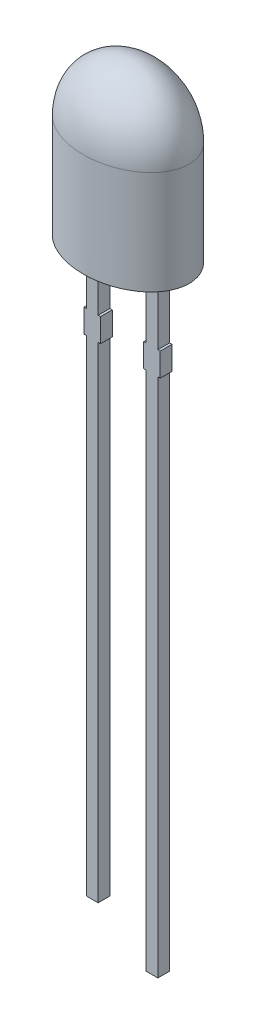
from build123d import *

# Parameters (mm, degrees)
SKETCH5_RX         = 2.6
SKETCH5_RY         = 1.9
EXTRUDE1_DEPTH     = 4.4
DOME3_HALF_AXIS_A  = 2.6
DOME3_HALF_AXIS_B  = 1.9
DOME3_HEIGHT       = 2.6
SKETCH3_W          = 0.5
SKETCH3_H          = 24.5
SKETCH3_H_2        = 26
SKETCH3_W_2        = 0.7
SKETCH3_H_3        = 1
EXTRUDE2_DEPTH     = 0.25
SKETCH6_W          = 0.025316456
SKETCH6_H          = 0.026582278
CUT_EXTRUDE1_DEPTH = 0.01


with BuildPart() as part:
    # Sketch5 → Extrude1 (new body)
    with BuildSketch(Plane(origin=(0, 0, 0), x_dir=(1, 0, 0), z_dir=(0, 1, 0))):
        with Locations(Location((0, 0), (0, 0, 180))):
            Ellipse(SKETCH5_RX, SKETCH5_RY)
    extrude(amount=EXTRUDE1_DEPTH)

    # Dome3: an elliptical dome of height H over an elliptical face of half axes A and B is half an ellipsoid of half axes A, B and H
    dome3_base = Plane((0, 4.4, 0), x_dir=(-1, 0, 0), z_dir=(0, 1, 0))  # on the face, x along the ellipse's major axis
    dome3_ball = dome3_base * scale(Sphere(1, mode=Mode.PRIVATE), by=(DOME3_HALF_AXIS_A, DOME3_HALF_AXIS_B, DOME3_HEIGHT), mode=Mode.PRIVATE)
    add(split(dome3_ball, bisect_by=dome3_base, keep=Keep.TOP, mode=Mode.PRIVATE))

    # Sketch3 → Extrude2 (add, symmetric)
    with BuildSketch(Plane.XY):
        with Locations((-1.27, -12.25)):
            Rectangle(SKETCH3_W, SKETCH3_H)
        with Locations((1.27, -13)):
            Rectangle(SKETCH3_W, SKETCH3_H_2)
        with Locations((-1.27, -3.35)):
            Rectangle(SKETCH3_W_2, SKETCH3_H_3)
        with Locations((1.27, -3.35)):
            Rectangle(SKETCH3_W_2, SKETCH3_H_3)
    extrude(amount=EXTRUDE2_DEPTH, both=True)

    # Sketch6 → Cut-Extrude1 (cut)
    with BuildSketch(Plane.XZ):
        Polygon((-0.686737084, 0.074683544), (-0.710194363, 0), (-0.734937243, 0), (-0.751353382, 0.050336234), (-0.76687949, 0), (-0.792611293, 0), (-0.815851009, 0.074683544), (-0.790673002, 0.074683544), (-0.77767854, 0.023200158), (-0.761262401, 0.074683544), (-0.739763192, 0.074683544), (-0.723445945, 0.023200158), (-0.71062949, 0.074683544), align=None)
        Polygon((-0.552559869, 0.074683544), (-0.576017148, 0), (-0.600760028, 0), (-0.617176167, 0.050336234), (-0.632702274, 0), (-0.658434078, 0), (-0.681673793, 0.074683544), (-0.656495787, 0.074683544), (-0.643501325, 0.023200158), (-0.627085186, 0.074683544), (-0.605585977, 0.074683544), (-0.58926873, 0.023200158), (-0.576452274, 0.074683544), align=None)
        Polygon((-0.418382654, 0.074683544), (-0.441839933, 0), (-0.466582812, 0), (-0.482998952, 0.050336234), (-0.498525059, 0), (-0.524256863, 0), (-0.547496578, 0.074683544), (-0.522318572, 0.074683544), (-0.50932411, 0.023200158), (-0.492907971, 0.074683544), (-0.471408762, 0.074683544), (-0.455091515, 0.023200158), (-0.442275059, 0.074683544), align=None)
        with Locations((-0.390534553, 0.013291139)):
            Rectangle(SKETCH6_W, SKETCH6_H)
        with BuildLine():
            add(Edge.make_bspline(
                [(-0.274078857, 0.031170886), (-0.274115346, 0.029948745), (-0.274186998, 0.027548867), (-0.274796715, 0.024041288), (-0.275790202, 0.020716583), (-0.277164319, 0.017553923), (-0.278953122, 0.014575304), (-0.281162712, 0.011795027), (-0.283727125, 0.009160227), (-0.286693335, 0.006754097), (-0.289973444, 0.00454972), (-0.29357102, 0.002652721), (-0.297449725, 0.001056238), (-0.301598311, -0.000282314), (-0.30604475, -0.001270894), (-0.310762279, -0.001994839), (-0.315755698, -0.002468169), (-0.319179276, -0.002510135), (-0.320934078, -0.002531646)],
                knots=[0, 0, 0, 0, 0.907352243, 1.781736951, 2.63548328, 3.47985091, 4.336556021, 5.208523475, 6.112432747, 7.062451073, 8.040435374, 9.043840564, 10.077958095, 11.152835584, 12.277940427, 13.457536469, 14.696825396, 16, 16, 16, 16], degree=3))
            add(Edge.make_bspline(
                [(-0.320934078, -0.002531646), (-0.322952334, -0.002507574), (-0.326861516, -0.002460949), (-0.332525041, -0.00203235), (-0.337793078, -0.001386211), (-0.342688793, -0.000419669), (-0.347293392, 0.000781096), (-0.35172666, 0.002072388), (-0.356007972, 0.003536803), (-0.358781061, 0.004636961), (-0.360154806, 0.005181962)],
                knots=[0, 0, 0, 0, 1.203215828, 2.33052265, 3.384689099, 4.366106119, 5.303329643, 6.221311756, 7.118865988, 8, 8, 8, 8], degree=3))
            Line((-0.360154806, 0.005181962), (-0.360154806, 0.029113924))
            Line((-0.360154806, 0.029113924), (-0.357306705, 0.029113924))
            add(Edge.make_bspline(
                [(-0.357306705, 0.029113924), (-0.355941391, 0.028032469), (-0.353218778, 0.025875908), (-0.348785545, 0.023113303), (-0.344137899, 0.02071114), (-0.339292428, 0.018737138), (-0.334395584, 0.017150814), (-0.329520206, 0.016057287), (-0.324754619, 0.015309938), (-0.321596049, 0.015229431), (-0.320044046, 0.015189873)],
                knots=[0, 0, 0, 0, 1.030622468, 2.055194264, 3.087043286, 4.125157485, 5.149848264, 6.130935704, 7.081611712, 8, 8, 8, 8], degree=3))
            add(Edge.make_bspline(
                [(-0.320044046, 0.015189873), (-0.31961527, 0.015190797), (-0.318697294, 0.015192774), (-0.317235767, 0.015320502), (-0.315583956, 0.015416078), (-0.313811447, 0.015623262), (-0.31201472, 0.015845123), (-0.31035232, 0.016220048), (-0.308842725, 0.016584915), (-0.307936204, 0.016952913), (-0.30750449, 0.017128165)],
                knots=[0, 0, 0, 0, 0.806402781, 1.726445712, 2.758724871, 3.919014682, 5.083870887, 6.16165551, 7.124521387, 8, 8, 8, 8], degree=3))
            add(Edge.make_bspline(
                [(-0.30750449, 0.017128165), (-0.307024927, 0.017356306), (-0.306082483, 0.017804654), (-0.304788884, 0.018614972), (-0.303621204, 0.019498437), (-0.302563832, 0.020463368), (-0.301689552, 0.021629118), (-0.301065685, 0.023037791), (-0.300720792, 0.024686809), (-0.300681768, 0.025862012), (-0.300661135, 0.026483386)],
                knots=[0, 0, 0, 0, 1.024747072, 2.013846092, 2.940605744, 3.850156746, 4.769278501, 5.73222711, 6.800942666, 8, 8, 8, 8], degree=3))
            add(Edge.make_bspline(
                [(-0.300661135, 0.026483386), (-0.30069298, 0.027029023), (-0.300755596, 0.028101907), (-0.301332789, 0.029637022), (-0.302242227, 0.03104619), (-0.303523817, 0.032314965), (-0.305116993, 0.033464498), (-0.307059376, 0.034446804), (-0.309309497, 0.035319991), (-0.310953568, 0.035737969), (-0.311816198, 0.035957278)],
                knots=[0, 0, 0, 0, 0.82557554, 1.623324704, 2.456147571, 3.35491006, 4.343819762, 5.427079081, 6.650009487, 8, 8, 8, 8], degree=3))
            add(Edge.make_bspline(
                [(-0.311816198, 0.035957278), (-0.313784825, 0.036405519), (-0.317823835, 0.037325169), (-0.323973659, 0.038463923), (-0.33010201, 0.039738783), (-0.334054776, 0.040945426), (-0.335985502, 0.04153481)],
                knots=[0, 0, 0, 0, 0.976100998, 2.002656142, 3.024398856, 4, 4, 4, 4], degree=3))
            add(Edge.make_bspline(
                [(-0.335985502, 0.04153481), (-0.33702402, 0.0418878), (-0.339045593, 0.042574928), (-0.341937105, 0.043736588), (-0.344598332, 0.045006418), (-0.347038046, 0.046361973), (-0.349238735, 0.047834513), (-0.351233002, 0.04937589), (-0.352996119, 0.05101593), (-0.354542924, 0.052755696), (-0.355867826, 0.054606399), (-0.357020211, 0.056551597), (-0.358002831, 0.058607016), (-0.358780869, 0.060777239), (-0.359405509, 0.063050895), (-0.359824491, 0.065428607), (-0.360123508, 0.067911736), (-0.360144231, 0.069606121), (-0.360154806, 0.070470728)],
                knots=[0, 0, 0, 0, 1.287047841, 2.5053592, 3.654260482, 4.74538952, 5.777514103, 6.75871007, 7.700244599, 8.599107454, 9.48590269, 10.366941872, 11.24940663, 12.154970331, 13.068988358, 14.012872203, 14.986013017, 16, 16, 16, 16], degree=3))
            add(Edge.make_bspline(
                [(-0.360154806, 0.070470728), (-0.360117504, 0.071626873), (-0.360044095, 0.073902145), (-0.359442666, 0.077231189), (-0.358416076, 0.080379926), (-0.357030013, 0.083383389), (-0.355201385, 0.086196475), (-0.35301659, 0.088875022), (-0.350392542, 0.091346614), (-0.347415421, 0.093646947), (-0.344128037, 0.095726346), (-0.340589053, 0.097556902), (-0.336819764, 0.099093554), (-0.332834217, 0.100367448), (-0.328615749, 0.101322119), (-0.324178516, 0.10204105), (-0.319504727, 0.102454232), (-0.316313305, 0.102505482), (-0.314684078, 0.102531646)],
                knots=[0, 0, 0, 0, 0.894990994, 1.761326291, 2.609044902, 3.454222546, 4.315366365, 5.200560057, 6.125081389, 7.100429509, 8.110379559, 9.133447974, 10.182136699, 11.259192205, 12.370181258, 13.528580438, 14.738335141, 16, 16, 16, 16], degree=3))
            add(Edge.make_bspline(
                [(-0.314684078, 0.102531646), (-0.313015384, 0.102509493), (-0.309680825, 0.102465225), (-0.304699486, 0.102086668), (-0.299745057, 0.101534356), (-0.294882633, 0.100685116), (-0.29019047, 0.099716884), (-0.285771356, 0.098617611), (-0.281691803, 0.097380104), (-0.27911815, 0.096425703), (-0.277876325, 0.09596519)],
                knots=[0, 0, 0, 0, 1.065407564, 2.129008667, 3.188544425, 4.247469455, 5.279542408, 6.247502114, 7.154394069, 8, 8, 8, 8], degree=3))
            Line((-0.277876325, 0.09596519), (-0.277876325, 0.073417722))
            Line((-0.277876325, 0.073417722), (-0.280704648, 0.073417722))
            add(Edge.make_bspline(
                [(-0.280704648, 0.073417722), (-0.281778151, 0.074217009), (-0.283968929, 0.075848175), (-0.287618533, 0.07794991), (-0.291586153, 0.079890002), (-0.295867779, 0.081581659), (-0.30032756, 0.083039666), (-0.304910318, 0.084059224), (-0.309536534, 0.084700931), (-0.312638238, 0.08477372), (-0.314189616, 0.084810127)],
                knots=[0, 0, 0, 0, 0.892265782, 1.820912499, 2.804518821, 3.836954028, 4.889985052, 5.931488012, 6.965393252, 8, 8, 8, 8], degree=3))
            add(Edge.make_bspline(
                [(-0.314189616, 0.084810127), (-0.315285221, 0.084788224), (-0.317482865, 0.08474429), (-0.320752056, 0.084359404), (-0.323992534, 0.083720552), (-0.326027216, 0.0829045), (-0.327045629, 0.082496044)],
                knots=[0, 0, 0, 0, 0.999122297, 2.004111588, 3.001004448, 4, 4, 4, 4], degree=3))
            add(Edge.make_bspline(
                [(-0.327045629, 0.082496044), (-0.327479358, 0.082294865), (-0.328346528, 0.081892641), (-0.32955407, 0.081113016), (-0.330675042, 0.080196673), (-0.331670625, 0.079143916), (-0.332515059, 0.077975562), (-0.333134085, 0.076707979), (-0.333508578, 0.075344098), (-0.333550924, 0.074408999), (-0.333572528, 0.073931962)],
                knots=[0, 0, 0, 0, 1.004925302, 2.009180302, 3.014392739, 4.04465309, 5.049195417, 6.035570224, 6.99785458, 8, 8, 8, 8], degree=3))
            add(Edge.make_bspline(
                [(-0.333572528, 0.073931962), (-0.333538089, 0.073293797), (-0.333472281, 0.072074321), (-0.332865697, 0.070358525), (-0.331880863, 0.068880091), (-0.330720259, 0.067885171), (-0.329603129, 0.067187733), (-0.328567469, 0.066677223), (-0.327358242, 0.066193864), (-0.325986995, 0.065696395), (-0.324450668, 0.065205208), (-0.322742111, 0.064729661), (-0.320859394, 0.064280365), (-0.319543519, 0.063994175), (-0.318857338, 0.063844937)],
                knots=[0, 0, 0, 0, 1.173816843, 2.243057204, 3.312297565, 4.415174738, 5.03266065, 5.73970059, 6.541434878, 7.433956553, 8.430083051, 9.515931566, 10.70464786, 12, 12, 12, 12], degree=3))
            add(Edge.make_bspline(
                [(-0.318857338, 0.063844937), (-0.317024415, 0.063469492), (-0.313429449, 0.062733121), (-0.308030225, 0.061620756), (-0.302525237, 0.060355397), (-0.298854085, 0.059203401), (-0.296942781, 0.058603639)],
                knots=[0, 0, 0, 0, 0.995749986, 1.952994291, 2.934271555, 4, 4, 4, 4], degree=3))
            add(Edge.make_bspline(
                [(-0.296942781, 0.058603639), (-0.295996292, 0.05828428), (-0.294144808, 0.057659563), (-0.291503261, 0.056574879), (-0.289054208, 0.055392789), (-0.286775937, 0.054170303), (-0.284713856, 0.052807087), (-0.282820632, 0.051392439), (-0.281137614, 0.04986433), (-0.279639664, 0.048251472), (-0.278321263, 0.04654104), (-0.277186299, 0.044702938), (-0.276223153, 0.042748409), (-0.275415022, 0.040675337), (-0.274837006, 0.038468269), (-0.274402948, 0.036141968), (-0.274112126, 0.033696653), (-0.27409007, 0.032022206), (-0.274078857, 0.031170886)],
                knots=[0, 0, 0, 0, 1.237386967, 2.420528625, 3.534815053, 4.605870898, 5.620827102, 6.594482803, 7.531295079, 8.432978826, 9.318460435, 10.202471551, 11.10474705, 12.014900263, 12.954095338, 13.926516828, 14.945802342, 16, 16, 16, 16], degree=3))
        make_face()
        with BuildLine():
            Line((-0.181673793, 0), (-0.205724426, 0))
            Line((-0.205724426, 0), (-0.205724426, 0.007832278))
            add(Edge.make_bspline(
                [(-0.205724426, 0.007832278), (-0.206817681, 0.007023611), (-0.208925461, 0.005464513), (-0.212099201, 0.003385748), (-0.215127922, 0.001602586), (-0.218049523, 6.0434e-05), (-0.221064878, -0.001130414), (-0.224292381, -0.00195227), (-0.227794645, -0.002453389), (-0.230221619, -0.002504981), (-0.231476009, -0.002531646)],
                knots=[0, 0, 0, 0, 1.150906677, 2.218931226, 3.20955724, 4.125565256, 5.012676028, 5.946647191, 6.938718366, 8, 8, 8, 8], degree=3))
            add(Edge.make_bspline(
                [(-0.231476009, -0.002531646), (-0.232492354, -0.002508916), (-0.234471472, -0.002464656), (-0.237348801, -0.002119919), (-0.240056113, -0.001581772), (-0.242572262, -0.000775916), (-0.244937608, 0.0001982), (-0.247089127, 0.001457288), (-0.249076815, 0.002916625), (-0.250880193, 0.00459356), (-0.252470812, 0.006514522), (-0.253857863, 0.008637273), (-0.255033675, 0.010971912), (-0.255975313, 0.013523278), (-0.256730246, 0.016281723), (-0.257254224, 0.019260929), (-0.257574804, 0.022448069), (-0.257606745, 0.024643197), (-0.25762316, 0.025771361)],
                knots=[0, 0, 0, 0, 1.108935798, 2.159418225, 3.158520219, 4.116592843, 5.038730546, 5.944611115, 6.829677354, 7.725673622, 8.624842385, 9.544872214, 10.487719724, 11.471363217, 12.50822837, 13.604887271, 14.769056852, 16, 16, 16, 16], degree=3))
            Line((-0.25762316, 0.025771361), (-0.25762316, 0.074683544))
            Line((-0.25762316, 0.074683544), (-0.233572528, 0.074683544))
            Line((-0.233572528, 0.074683544), (-0.233572528, 0.03710443))
            add(Edge.make_bspline(
                [(-0.233572528, 0.03710443), (-0.233570892, 0.036187959), (-0.233567761, 0.034433744), (-0.233485423, 0.031927937), (-0.233364522, 0.029659765), (-0.233225817, 0.027617736), (-0.232972801, 0.025770985), (-0.232595092, 0.024104824), (-0.232124266, 0.022585222), (-0.231659947, 0.021678521), (-0.231436452, 0.021242089)],
                knots=[0, 0, 0, 0, 1.361401701, 2.605856924, 3.723918663, 4.735739235, 5.645738665, 6.489217889, 7.27279937, 8, 8, 8, 8], degree=3))
            add(Edge.make_bspline(
                [(-0.231436452, 0.021242089), (-0.231206412, 0.020843441), (-0.230754173, 0.020059734), (-0.229834362, 0.019052586), (-0.228758379, 0.018215679), (-0.22748874, 0.017543035), (-0.225995659, 0.017059332), (-0.224263659, 0.016712585), (-0.222277643, 0.016498761), (-0.220868724, 0.016470599), (-0.22012316, 0.016455696)],
                knots=[0, 0, 0, 0, 0.849057291, 1.669173542, 2.503217716, 3.359509317, 4.311793648, 5.394940091, 6.621469141, 8, 8, 8, 8], degree=3))
            add(Edge.make_bspline(
                [(-0.22012316, 0.016455696), (-0.219581896, 0.016473154), (-0.218469018, 0.016509047), (-0.216763806, 0.016738976), (-0.214974778, 0.017100632), (-0.212460581, 0.017759655), (-0.209284436, 0.018938834), (-0.206920296, 0.020297635), (-0.205724426, 0.020984968)],
                knots=[0, 0, 0, 0, 0.638164724, 1.312110757, 2.025558264, 2.789159289, 4.375836335, 6, 6, 6, 6], degree=3))
            Line((-0.205724426, 0.020984968), (-0.205724426, 0.074683544))
            Line((-0.205724426, 0.074683544), (-0.181673793, 0.074683544))
            Line((-0.181673793, 0.074683544), (-0.181673793, 0))
        make_face()
        with BuildLine():
            Line((-0.084205439, 0), (-0.108256072, 0))
            Line((-0.108256072, 0), (-0.108256072, 0.037579114))
            add(Edge.make_bspline(
                [(-0.108256072, 0.037579114), (-0.108276396, 0.039109587), (-0.108316931, 0.042162), (-0.108650511, 0.045918775), (-0.10898422, 0.048766566), (-0.109361043, 0.050602633), (-0.10979123, 0.052150969), (-0.110203675, 0.053036706), (-0.110392148, 0.053441456)],
                knots=[0, 0, 0, 0, 1.709235885, 3.408940626, 4.211008593, 4.910095588, 5.501954032, 6, 6, 6, 6], degree=3))
            add(Edge.make_bspline(
                [(-0.110392148, 0.053441456), (-0.110636576, 0.053839578), (-0.111115813, 0.054620153), (-0.112053628, 0.055632175), (-0.113150277, 0.056468389), (-0.114429001, 0.057133339), (-0.115913654, 0.057619237), (-0.117626328, 0.058005896), (-0.119612299, 0.058174456), (-0.121019667, 0.058209366), (-0.121764774, 0.058227848)],
                knots=[0, 0, 0, 0, 0.860145871, 1.686437142, 2.528070002, 3.393017362, 4.331453407, 5.402595683, 6.624848233, 8, 8, 8, 8], degree=3))
            add(Edge.make_bspline(
                [(-0.121764774, 0.058227848), (-0.122896664, 0.058171268), (-0.125207897, 0.058055735), (-0.128069188, 0.057342143), (-0.130396064, 0.056529846), (-0.132241685, 0.055755609), (-0.134158214, 0.054800984), (-0.135441638, 0.05407391), (-0.136104173, 0.053698576)],
                knots=[0, 0, 0, 0, 1.338419466, 2.732951426, 3.468143565, 4.254837763, 5.099104234, 6, 6, 6, 6], degree=3))
            Line((-0.136104173, 0.053698576), (-0.136104173, 0))
            Line((-0.136104173, 0), (-0.160154806, 0))
            Line((-0.160154806, 0), (-0.160154806, 0.074683544))
            Line((-0.160154806, 0.074683544), (-0.136104173, 0.074683544))
            Line((-0.136104173, 0.074683544), (-0.136104173, 0.066851266))
            add(Edge.make_bspline(
                [(-0.136104173, 0.066851266), (-0.135046936, 0.067657704), (-0.13298896, 0.069227483), (-0.129812208, 0.071260892), (-0.126741496, 0.073070749), (-0.123686974, 0.074582883), (-0.120562476, 0.075781483), (-0.117294845, 0.076597086), (-0.113878133, 0.077140034), (-0.11154146, 0.077189846), (-0.110352591, 0.07721519)],
                knots=[0, 0, 0, 0, 1.126064518, 2.191951536, 3.19307265, 4.144813015, 5.076393104, 6.021983703, 6.993610568, 8, 8, 8, 8], degree=3))
            add(Edge.make_bspline(
                [(-0.110352591, 0.07721519), (-0.109356319, 0.077189801), (-0.10741142, 0.077140237), (-0.10457666, 0.076830527), (-0.101905239, 0.076279863), (-0.099412964, 0.075482034), (-0.097070348, 0.074496421), (-0.094908391, 0.07326491), (-0.092916365, 0.071806471), (-0.091087796, 0.070145529), (-0.089457615, 0.068255571), (-0.088038129, 0.066139198), (-0.086866706, 0.06379047), (-0.085857874, 0.061243333), (-0.085123649, 0.058465563), (-0.084597198, 0.055474797), (-0.084246768, 0.052269615), (-0.084219491, 0.050053715), (-0.084205439, 0.048912184)],
                knots=[0, 0, 0, 0, 1.088441561, 2.124831547, 3.110816719, 4.062969431, 4.979391633, 5.88258537, 6.774334107, 7.671621258, 8.575503974, 9.49441354, 10.447872957, 11.437639084, 12.482478955, 13.580222388, 14.753440527, 16, 16, 16, 16], degree=3))
            Line((-0.084205439, 0.048912184), (-0.084205439, 0))
        make_face()
        Polygon((0.01073127, 0), (-0.061420629, 0), (-0.061420629, 0.1), (-0.036104173, 0.1), (-0.036104173, 0.018987342), (0.01073127, 0.018987342), align=None)
        Polygon((0.098073042, 0), (0.025921143, 0), (0.025921143, 0.1), (0.098073042, 0.1), (0.098073042, 0.081012658), (0.051237599, 0.081012658), (0.051237599, 0.063291139), (0.094275574, 0.063291139), (0.094275574, 0.044303797), (0.051237599, 0.044303797), (0.051237599, 0.018987342), (0.098073042, 0.018987342), align=None)
        with BuildLine():
            add(Edge.make_bspline(
                [(0.214528738, 0.049901108), (0.214509423, 0.048753419), (0.214471171, 0.046480533), (0.21417598, 0.043115726), (0.213649954, 0.039850051), (0.212970773, 0.036665802), (0.212048267, 0.033586874), (0.210966553, 0.030579297), (0.209656907, 0.027673804), (0.208152055, 0.024872369), (0.206502583, 0.022200266), (0.204727834, 0.019680058), (0.202882054, 0.01729684), (0.200892742, 0.015101946), (0.19881356, 0.013059926), (0.196638032, 0.011169112), (0.194332967, 0.009465681), (0.192725805, 0.008442797), (0.191921935, 0.007931171)],
                knots=[0, 0, 0, 0, 1.105570398, 2.18947457, 3.250358341, 4.290584537, 5.323553275, 6.344225964, 7.367641686, 8.3905646, 9.405808457, 10.390761353, 11.358902336, 12.307789878, 13.241960776, 14.165076779, 15.082208636, 16, 16, 16, 16], degree=3))
            add(Edge.make_bspline(
                [(0.191921935, 0.007931171), (0.190682714, 0.007219001), (0.188197949, 0.005791028), (0.184214002, 0.004122897), (0.180082884, 0.00271494), (0.17572433, 0.001666751), (0.171077981, 0.000938018), (0.166083324, 0.000374967), (0.160682197, 7.4603e-05), (0.156947314, 2.5434e-05), (0.155015289, 0)],
                knots=[0, 0, 0, 0, 0.896298978, 1.797171328, 2.70531317, 3.633678302, 4.606491125, 5.655688921, 6.787306437, 8, 8, 8, 8], degree=3))
            Line((0.155015289, 0), (0.119592029, 0))
            Line((0.119592029, 0), (0.119592029, 0.1))
            Line((0.119592029, 0.1), (0.156023991, 0.1))
            add(Edge.make_bspline(
                [(0.156023991, 0.1), (0.158002715, 0.099983305), (0.161819428, 0.099951101), (0.167329846, 0.099535133), (0.172428226, 0.098935613), (0.177112805, 0.098008921), (0.181421211, 0.09690027), (0.185352233, 0.095537234), (0.188964122, 0.094038962), (0.19114295, 0.092765215), (0.192198833, 0.092147943)],
                knots=[0, 0, 0, 0, 1.267192274, 2.444256634, 3.537982003, 4.553396635, 5.500903572, 6.385021601, 7.217363933, 8, 8, 8, 8], degree=3))
            add(Edge.make_bspline(
                [(0.192198833, 0.092147943), (0.193049787, 0.091611402), (0.194741911, 0.090544489), (0.197143126, 0.088762637), (0.199372553, 0.08680656), (0.201501057, 0.084754741), (0.203480871, 0.082551853), (0.205324084, 0.08021315), (0.20702785, 0.077735043), (0.208586006, 0.075125623), (0.210006091, 0.072395383), (0.211198171, 0.069523038), (0.212237533, 0.066540165), (0.213083615, 0.063441225), (0.213739945, 0.060223835), (0.214186029, 0.056886355), (0.214469461, 0.053433167), (0.214508813, 0.051088373), (0.214528738, 0.049901108)],
                knots=[0, 0, 0, 0, 0.964043478, 1.917004671, 2.862223898, 3.805158963, 4.749279098, 5.698713747, 6.657523689, 7.629652222, 8.610369353, 9.604453025, 10.607693792, 11.636365947, 12.681120053, 13.752669011, 14.862083412, 16, 16, 16, 16], degree=3))
        make_face()
        with BuildLine():
            add(Edge.make_bspline(
                [(0.18794646, 0.050059335), (0.187935989, 0.050864049), (0.18791545, 0.052442541), (0.187727127, 0.054758716), (0.187456539, 0.056984766), (0.187067406, 0.059128399), (0.186526973, 0.061178546), (0.185894792, 0.063140116), (0.185167701, 0.065019039), (0.184286771, 0.066796698), (0.183312947, 0.068505036), (0.182165503, 0.070090563), (0.180917152, 0.071603446), (0.179538869, 0.073031431), (0.177995928, 0.074337327), (0.176335826, 0.075567403), (0.174535468, 0.076695729), (0.17326248, 0.077355779), (0.172618137, 0.077689873)],
                knots=[0, 0, 0, 0, 1.152052275, 2.259818351, 3.325348653, 4.362224493, 5.376551665, 6.358740615, 7.312387502, 8.258104984, 9.197203025, 10.124507262, 11.056413058, 12.004389423, 12.961766972, 13.947352551, 14.961020569, 16, 16, 16, 16], degree=3))
            add(Edge.make_bspline(
                [(0.172618137, 0.077689873), (0.171943239, 0.077996585), (0.170605545, 0.07860451), (0.168534722, 0.079335702), (0.166445339, 0.079908538), (0.164243739, 0.080339396), (0.16177398, 0.080661327), (0.158848398, 0.080858585), (0.155392488, 0.081000755), (0.152905773, 0.081008506), (0.151573833, 0.081012658)],
                knots=[0, 0, 0, 0, 0.826967603, 1.639107464, 2.447640171, 3.242670507, 4.14065217, 5.225198036, 6.513753944, 8, 8, 8, 8], degree=3))
            Line((0.151573833, 0.081012658), (0.144908485, 0.081012658))
            Line((0.144908485, 0.081012658), (0.144908485, 0.018987342))
            Line((0.144908485, 0.018987342), (0.151573833, 0.018987342))
            add(Edge.make_bspline(
                [(0.151573833, 0.018987342), (0.152332041, 0.018992088), (0.153795807, 0.01900125), (0.155912045, 0.019044363), (0.157877861, 0.019091077), (0.159682666, 0.019208115), (0.161335009, 0.019278614), (0.162821157, 0.019462285), (0.164158106, 0.01959676), (0.165730587, 0.019874483), (0.167585774, 0.020280458), (0.169752563, 0.020963616), (0.171893262, 0.02181319), (0.173281813, 0.022498269), (0.173982852, 0.022844146)],
                knots=[0, 0, 0, 0, 1.186805873, 2.291202465, 3.313317863, 4.264127762, 5.122212376, 5.900577546, 6.607154111, 7.224697658, 8.398873738, 9.57716935, 10.776782771, 12, 12, 12, 12], degree=3))
            add(Edge.make_bspline(
                [(0.173982852, 0.022844146), (0.174567966, 0.023185663), (0.175721887, 0.023859181), (0.177345426, 0.024993232), (0.178853016, 0.026201042), (0.180249494, 0.027489182), (0.18151108, 0.028878568), (0.182667167, 0.030338034), (0.183672554, 0.031898355), (0.184911808, 0.034087181), (0.186158898, 0.037111938), (0.187191298, 0.041084692), (0.187830445, 0.045443604), (0.187906798, 0.048481345), (0.18794646, 0.050059335)],
                knots=[0, 0, 0, 0, 0.755237594, 1.489427721, 2.205882609, 2.908165467, 3.605466573, 4.296695275, 4.981837198, 5.673065901, 7.099889822, 8.61390339, 10.241051878, 12, 12, 12, 12], degree=3))
        make_face(mode=Mode.SUBTRACT)
        with Locations((0.246174308, 0.013291139)):
            Rectangle(SKETCH6_W, SKETCH6_H)
        with BuildLine():
            add(Edge.make_bspline(
                [(0.320818295, -0.002531646), (0.319228179, -0.002509842), (0.316107035, -0.002467046), (0.311535747, -0.001990018), (0.307170381, -0.001272721), (0.303024757, -0.000250402), (0.299114214, 0.001090117), (0.295459264, 0.002760123), (0.292042593, 0.004727319), (0.289980673, 0.006312215), (0.288955162, 0.007100475)],
                knots=[0, 0, 0, 0, 1.123701398, 2.205645569, 3.245398653, 4.249180969, 5.220497262, 6.163202923, 7.086456062, 8, 8, 8, 8], degree=3))
            add(Edge.make_bspline(
                [(0.288955162, 0.007100475), (0.288003528, 0.007955308), (0.286103938, 0.009661668), (0.283636311, 0.012632212), (0.281518235, 0.015921185), (0.279705979, 0.019512837), (0.278274028, 0.023432723), (0.277281493, 0.027682617), (0.276653889, 0.032239947), (0.276587937, 0.035388151), (0.276554055, 0.037005538)],
                knots=[0, 0, 0, 0, 0.916342154, 1.829140869, 2.758848968, 3.716597128, 4.708179637, 5.743612459, 6.840783343, 8, 8, 8, 8], degree=3))
            add(Edge.make_bspline(
                [(0.276554055, 0.037005538), (0.276592815, 0.038708765), (0.276667938, 0.042009845), (0.277331698, 0.046782033), (0.27840131, 0.051199713), (0.279938868, 0.055251622), (0.28186931, 0.058944813), (0.284133803, 0.062316648), (0.286754329, 0.065359572), (0.288761467, 0.067105012), (0.28976608, 0.067978639)],
                knots=[0, 0, 0, 0, 1.171797512, 2.271099083, 3.308930235, 4.294129479, 5.24602549, 6.17106565, 7.084581485, 8, 8, 8, 8], degree=3))
            add(Edge.make_bspline(
                [(0.28976608, 0.067978639), (0.290791864, 0.068747418), (0.292855822, 0.070294261), (0.296255362, 0.072189074), (0.299867574, 0.073793591), (0.303698691, 0.075039477), (0.307679209, 0.075988014), (0.31174475, 0.076714986), (0.315891117, 0.077135011), (0.318681302, 0.077188335), (0.320086491, 0.07721519)],
                knots=[0, 0, 0, 0, 0.952097844, 1.915695341, 2.885641886, 3.886921822, 4.905719434, 5.925883802, 6.95543633, 8, 8, 8, 8], degree=3))
            add(Edge.make_bspline(
                [(0.320086491, 0.07721519), (0.321333218, 0.077198226), (0.323784705, 0.07716487), (0.327385639, 0.076842213), (0.330834223, 0.076312048), (0.334131535, 0.075568454), (0.337304683, 0.074675655), (0.340364156, 0.073644375), (0.343328972, 0.072506434), (0.34522965, 0.071622218), (0.346174308, 0.071182753)],
                knots=[0, 0, 0, 0, 1.107671842, 2.178058178, 3.209662749, 4.206063564, 5.179815947, 6.137646632, 7.07438927, 8, 8, 8, 8], degree=3))
            Line((0.346174308, 0.071182753), (0.346174308, 0.050632911))
            Line((0.346174308, 0.050632911), (0.342831745, 0.050632911))
            add(Edge.make_bspline(
                [(0.342831745, 0.050632911), (0.342332976, 0.051051138), (0.341251041, 0.051958362), (0.339449688, 0.053359375), (0.337316178, 0.054909941), (0.33566497, 0.055795944), (0.334781903, 0.056269778)],
                knots=[0, 0, 0, 0, 0.792878214, 1.719922066, 2.780612869, 4, 4, 4, 4], degree=3))
            add(Edge.make_bspline(
                [(0.334781903, 0.056269778), (0.333854243, 0.056712647), (0.331947215, 0.05762307), (0.329387237, 0.058442614), (0.327198206, 0.059021151), (0.325386323, 0.05927396), (0.323452903, 0.059464309), (0.322117632, 0.059483704), (0.321431428, 0.059493671)],
                knots=[0, 0, 0, 0, 1.33256682, 2.739414054, 3.480190821, 4.267897792, 5.109861573, 6, 6, 6, 6], degree=3))
            add(Edge.make_bspline(
                [(0.321431428, 0.059493671), (0.32066588, 0.059474111), (0.319182282, 0.059436206), (0.31702068, 0.059159284), (0.315002604, 0.058680549), (0.313098195, 0.058042138), (0.311359449, 0.057145898), (0.309716919, 0.05613363), (0.308242443, 0.054879123), (0.306900496, 0.053461382), (0.305713012, 0.051870869), (0.30468626, 0.050144381), (0.303803534, 0.048286488), (0.30310164, 0.04628858), (0.30254413, 0.044158718), (0.302154565, 0.041895908), (0.301912786, 0.03949631), (0.301884844, 0.037850015), (0.30187051, 0.037005538)],
                knots=[0, 0, 0, 0, 1.087094245, 2.106738054, 3.087824582, 4.029427112, 4.95060567, 5.859714611, 6.763601524, 7.690850518, 8.627131371, 9.576106403, 10.539384251, 11.543302637, 12.578856349, 13.662518017, 14.800975475, 16, 16, 16, 16], degree=3))
            add(Edge.make_bspline(
                [(0.30187051, 0.037005538), (0.301885285, 0.036141382), (0.301913991, 0.034462369), (0.302147505, 0.032020758), (0.302563396, 0.029739327), (0.303134644, 0.027614007), (0.303858992, 0.025647989), (0.304764109, 0.023850592), (0.305800466, 0.022193785), (0.307045024, 0.020731173), (0.308408908, 0.019414851), (0.309923799, 0.018278717), (0.311583038, 0.017330572), (0.313365219, 0.016526109), (0.31529826, 0.015947711), (0.317354796, 0.015511019), (0.319544351, 0.015222462), (0.321054705, 0.015200899), (0.321826998, 0.015189873)],
                knots=[0, 0, 0, 0, 1.230336593, 2.390482092, 3.487897344, 4.52859895, 5.520747884, 6.465347575, 7.38981449, 8.296085817, 9.192433006, 10.084246191, 10.984321635, 11.908883871, 12.862027947, 13.850751296, 14.901019963, 16, 16, 16, 16], degree=3))
            add(Edge.make_bspline(
                [(0.321826998, 0.015189873), (0.32255284, 0.015198097), (0.323967843, 0.015214128), (0.326026265, 0.015430195), (0.327980182, 0.015709521), (0.329814729, 0.016150798), (0.331518978, 0.016685682), (0.333084631, 0.017256508), (0.334497238, 0.017860788), (0.335358572, 0.018328404), (0.335770827, 0.018552215)],
                knots=[0, 0, 0, 0, 1.200879421, 2.341068892, 3.423000803, 4.465923194, 5.460027553, 6.378409259, 7.223869634, 8, 8, 8, 8], degree=3))
            add(Edge.make_bspline(
                [(0.335770827, 0.018552215), (0.336479183, 0.018979901), (0.337840557, 0.01980186), (0.339665675, 0.02122232), (0.3413098, 0.02262876), (0.342333905, 0.023585528), (0.342831745, 0.024050633)],
                knots=[0, 0, 0, 0, 1.105932972, 2.12546697, 3.088749538, 4, 4, 4, 4], degree=3))
            Line((0.342831745, 0.024050633), (0.346174308, 0.024050633))
            Line((0.346174308, 0.024050633), (0.346174308, 0.003342563))
            add(Edge.make_bspline(
                [(0.346174308, 0.003342563), (0.345228931, 0.002905021), (0.343337951, 0.002029832), (0.340423173, 0.000876681), (0.33742993, -9.6198e-05), (0.334378701, -0.000988545), (0.331209069, -0.00168674), (0.327891719, -0.00217597), (0.324410415, -0.002477709), (0.322031999, -0.002513421), (0.320818295, -0.002531646)],
                knots=[0, 0, 0, 0, 0.952024047, 1.90427691, 2.862762905, 3.827874523, 4.80891974, 5.826446878, 6.890837857, 8, 8, 8, 8], degree=3))
        make_face()
        with BuildLine():
            add(Edge.make_bspline(
                [(0.438579371, 0.037302215), (0.438554451, 0.035797383), (0.438505876, 0.032864062), (0.437969668, 0.028591242), (0.437146205, 0.024560801), (0.436012881, 0.020759963), (0.434495027, 0.017216917), (0.432652613, 0.013920963), (0.430479022, 0.010868781), (0.427988704, 0.008078554), (0.425187218, 0.005580362), (0.422113453, 0.003384169), (0.418743586, 0.001577121), (0.41513484, 5.0572e-05), (0.411245533, -0.001105529), (0.407086438, -0.00192348), (0.402668929, -0.002457811), (0.399630563, -0.002506624), (0.398073042, -0.002531646)],
                knots=[0, 0, 0, 0, 1.120122129, 2.18341868, 3.201215738, 4.181270334, 5.131540819, 6.065757527, 6.988093576, 7.916512302, 8.844931028, 9.778115023, 10.722851943, 11.686686084, 12.691660064, 13.738321946, 14.84062285, 16, 16, 16, 16], degree=3))
            add(Edge.make_bspline(
                [(0.398073042, -0.002531646), (0.396515494, -0.002506706), (0.393477075, -0.002458054), (0.389059941, -0.001922584), (0.384905722, -0.001109866), (0.38102107, 5.9369e-05), (0.377406759, 0.001571459), (0.374032932, 0.003384901), (0.37095875, 0.005580154), (0.368157548, 0.008078664), (0.365666511, 0.010868549), (0.363495506, 0.013921779), (0.361644567, 0.017211571), (0.360164174, 0.020768846), (0.358991643, 0.024556054), (0.358178863, 0.028592052), (0.357639547, 0.032863843), (0.357591408, 0.035797309), (0.357566713, 0.037302215)],
                knots=[0, 0, 0, 0, 1.159424321, 2.261770074, 3.308474541, 4.308788811, 5.277191138, 6.221966496, 7.15518846, 8.08364496, 9.01210146, 9.934475036, 10.868729753, 11.817121636, 12.798654016, 13.816492484, 14.879832297, 16, 16, 16, 16], degree=3))
            add(Edge.make_bspline(
                [(0.357566713, 0.037302215), (0.357591836, 0.038813639), (0.357640921, 0.041766649), (0.358176291, 0.046065522), (0.358994308, 0.050126172), (0.36015434, 0.053934486), (0.361670613, 0.057486086), (0.363511638, 0.06078819), (0.365708106, 0.063834765), (0.368217605, 0.066624517), (0.371029398, 0.069120898), (0.37412333, 0.071293803), (0.377475249, 0.073130461), (0.381082449, 0.074652294), (0.384969004, 0.075786859), (0.389105947, 0.076604438), (0.39350334, 0.07714251), (0.396522079, 0.077190522), (0.398073042, 0.07721519)],
                knots=[0, 0, 0, 0, 1.124034801, 2.196132384, 3.217834281, 4.203147447, 5.152578239, 6.085969439, 7.010345409, 7.941219594, 8.872481455, 9.802010446, 10.748267785, 11.711250247, 12.709230373, 13.754967386, 14.846549946, 16, 16, 16, 16], degree=3))
            add(Edge.make_bspline(
                [(0.398073042, 0.07721519), (0.399643786, 0.077190478), (0.402701962, 0.077142364), (0.407145291, 0.076606025), (0.411319421, 0.075793499), (0.41521703, 0.074625429), (0.418841038, 0.07312216), (0.422188214, 0.071267213), (0.425273173, 0.069092863), (0.428041435, 0.066563035), (0.430525194, 0.063768081), (0.432687551, 0.060710401), (0.434523027, 0.057402825), (0.435998769, 0.053840949), (0.437172972, 0.050048317), (0.437993384, 0.046013891), (0.438499535, 0.041738984), (0.438552297, 0.038806841), (0.438579371, 0.037302215)],
                knots=[0, 0, 0, 0, 1.167473013, 2.273023816, 3.322954552, 4.326451713, 5.293391623, 6.234801871, 7.166614545, 8.093305908, 9.017100806, 9.942078766, 10.872536262, 11.824015763, 12.804065898, 13.820367293, 14.881523901, 16, 16, 16, 16], degree=3))
        make_face()
        with BuildLine():
            add(Edge.make_bspline(
                [(0.408872093, 0.018809335), (0.409226839, 0.019309529), (0.409948788, 0.020327481), (0.410824728, 0.022022673), (0.411584382, 0.02385394), (0.412203068, 0.025880223), (0.412713211, 0.028178), (0.41301483, 0.030834932), (0.413247645, 0.033869818), (0.413257625, 0.036022626), (0.413262916, 0.037163766)],
                knots=[0, 0, 0, 0, 0.765094823, 1.557058493, 2.376706509, 3.238810155, 4.199844458, 5.312104478, 6.575226644, 8, 8, 8, 8], degree=3))
            add(Edge.make_bspline(
                [(0.413262916, 0.037163766), (0.413245227, 0.038238647), (0.413211336, 0.040298004), (0.413024967, 0.043257767), (0.412676292, 0.045941193), (0.412178414, 0.048358589), (0.411568644, 0.050529277), (0.410842708, 0.05247164), (0.410004191, 0.054190242), (0.409318724, 0.055195473), (0.408990764, 0.055676424)],
                knots=[0, 0, 0, 0, 1.337076348, 2.561692668, 3.686680134, 4.69989255, 5.629188848, 6.488203485, 7.276684665, 8, 8, 8, 8], degree=3))
            add(Edge.make_bspline(
                [(0.408990764, 0.055676424), (0.40865219, 0.056114261), (0.40799094, 0.056969378), (0.406833187, 0.058073012), (0.405552705, 0.058950962), (0.404171858, 0.059619627), (0.402731149, 0.060133136), (0.401225027, 0.060489178), (0.399668467, 0.060710341), (0.398607788, 0.060743019), (0.398073042, 0.060759494)],
                knots=[0, 0, 0, 0, 1.058499091, 2.067300666, 3.047512573, 4.018335651, 4.996351322, 5.969796037, 6.97646375, 8, 8, 8, 8], degree=3))
            add(Edge.make_bspline(
                [(0.398073042, 0.060759494), (0.39754514, 0.060748464), (0.39651258, 0.06072689), (0.395009503, 0.060548373), (0.39359385, 0.060248374), (0.392248685, 0.059844189), (0.390963536, 0.059232812), (0.389732259, 0.058383995), (0.388516873, 0.057307415), (0.387778544, 0.05645708), (0.387392662, 0.056012658)],
                knots=[0, 0, 0, 0, 1.04189444, 2.037910168, 2.982338511, 3.896140384, 4.804271323, 5.778885192, 6.839150358, 8, 8, 8, 8], degree=3))
            add(Edge.make_bspline(
                [(0.387392662, 0.056012658), (0.387057229, 0.055538991), (0.386353238, 0.054544883), (0.38550405, 0.052824513), (0.384734751, 0.050879022), (0.384055462, 0.048687886), (0.383524277, 0.046220346), (0.383166089, 0.043461733), (0.382921408, 0.040411799), (0.382896293, 0.038278492), (0.382883169, 0.037163766)],
                knots=[0, 0, 0, 0, 0.70629823, 1.482341141, 2.329662943, 3.254583898, 4.274063958, 5.401087491, 6.641978366, 8, 8, 8, 8], degree=3))
            add(Edge.make_bspline(
                [(0.382883169, 0.037163766), (0.382889109, 0.036161027), (0.382900614, 0.034218895), (0.383142809, 0.031416563), (0.383429637, 0.028808119), (0.383916207, 0.026420066), (0.384488045, 0.02423489), (0.385236088, 0.022283296), (0.386059428, 0.020528223), (0.386759782, 0.019500484), (0.387095985, 0.01900712)],
                knots=[0, 0, 0, 0, 1.270983191, 2.461674417, 3.564986371, 4.596265355, 5.549463796, 6.425202083, 7.244022889, 8, 8, 8, 8], degree=3))
            add(Edge.make_bspline(
                [(0.387095985, 0.01900712), (0.387436348, 0.018590345), (0.388107394, 0.017768648), (0.389255189, 0.016692507), (0.390523162, 0.01581795), (0.39187278, 0.01509496), (0.393339372, 0.014560577), (0.394899657, 0.014190644), (0.396557107, 0.013971505), (0.397689993, 0.013940134), (0.398270827, 0.013924051)],
                knots=[0, 0, 0, 0, 1.010886179, 1.993025998, 2.945391046, 3.898964935, 4.863589088, 5.87059323, 6.908247091, 8, 8, 8, 8], degree=3))
            add(Edge.make_bspline(
                [(0.398270827, 0.013924051), (0.399278455, 0.013976572), (0.401276262, 0.014080705), (0.403691683, 0.014797112), (0.405493341, 0.01565209), (0.406748139, 0.016511499), (0.407886449, 0.017572268), (0.408539314, 0.018391669), (0.408872093, 0.018809335)],
                knots=[0, 0, 0, 0, 1.49343762, 2.961012893, 3.700518105, 4.446788108, 5.208294864, 6, 6, 6, 6], degree=3))
        make_face(mode=Mode.SUBTRACT)
        with BuildLine():
            Line((0.529718612, 0.053698576), (0.529718612, 0))
            Line((0.529718612, 0), (0.505667979, 0))
            Line((0.505667979, 0), (0.505667979, 0.037856013))
            add(Edge.make_bspline(
                [(0.505667979, 0.037856013), (0.505661712, 0.038746012), (0.50564969, 0.040453577), (0.505627177, 0.042913907), (0.505511806, 0.045161249), (0.505415253, 0.047208585), (0.505216569, 0.04906497), (0.504938898, 0.050744679), (0.504510043, 0.052247675), (0.504102617, 0.05314879), (0.503907694, 0.053579905)],
                knots=[0, 0, 0, 0, 1.33997484, 2.570892857, 3.703483919, 4.727540125, 5.655929516, 6.512630168, 7.288405602, 8, 8, 8, 8], degree=3))
            add(Edge.make_bspline(
                [(0.503907694, 0.053579905), (0.503697768, 0.053965272), (0.503281644, 0.054729165), (0.502413599, 0.055697026), (0.50140529, 0.056507671), (0.500225129, 0.057149126), (0.498846445, 0.057647288), (0.497231324, 0.057996634), (0.495367466, 0.058177036), (0.494045178, 0.058210273), (0.493345985, 0.058227848)],
                knots=[0, 0, 0, 0, 0.859345536, 1.703436662, 2.532498256, 3.390183975, 4.328249457, 5.402602062, 6.626559876, 8, 8, 8, 8], degree=3))
            add(Edge.make_bspline(
                [(0.493345985, 0.058227848), (0.492758646, 0.058204453), (0.491578671, 0.058157451), (0.489814557, 0.057912509), (0.488086947, 0.057417126), (0.48586786, 0.056579415), (0.483268997, 0.055355223), (0.481301066, 0.054237761), (0.480351523, 0.053698576)],
                knots=[0, 0, 0, 0, 0.759382397, 1.525614786, 2.294447385, 3.076151307, 4.589219126, 6, 6, 6, 6], degree=3))
            Line((0.480351523, 0.053698576), (0.480351523, 0))
            Line((0.480351523, 0), (0.45630089, 0))
            Line((0.45630089, 0), (0.45630089, 0.074683544))
            Line((0.45630089, 0.074683544), (0.480351523, 0.074683544))
            Line((0.480351523, 0.074683544), (0.480351523, 0.066851266))
            add(Edge.make_bspline(
                [(0.480351523, 0.066851266), (0.481372612, 0.067632646), (0.483355152, 0.069149769), (0.486368428, 0.071197097), (0.489321321, 0.072952681), (0.492214008, 0.074500577), (0.495167687, 0.075740192), (0.498266091, 0.076583131), (0.501509381, 0.077114203), (0.503727589, 0.077181118), (0.504857061, 0.07721519)],
                knots=[0, 0, 0, 0, 1.136109262, 2.205863928, 3.217041414, 4.170849475, 5.103496751, 6.040664374, 7.002340634, 8, 8, 8, 8], degree=3))
            add(Edge.make_bspline(
                [(0.504857061, 0.07721519), (0.506060296, 0.077183436), (0.508411934, 0.077121375), (0.511823976, 0.076452235), (0.515039422, 0.075447167), (0.51799704, 0.073958348), (0.520717238, 0.072116896), (0.523130398, 0.069860157), (0.525220293, 0.067192914), (0.526311844, 0.065187687), (0.52687051, 0.064161392)],
                knots=[0, 0, 0, 0, 1.065971563, 2.0833675, 3.072814207, 4.045738768, 5.009267307, 5.977487593, 6.964858173, 8, 8, 8, 8], degree=3))
            add(Edge.make_bspline(
                [(0.52687051, 0.064161392), (0.528052595, 0.065138357), (0.530356251, 0.067042273), (0.533909867, 0.069584895), (0.537388946, 0.071839452), (0.540829466, 0.073748277), (0.54422991, 0.075298831), (0.547612417, 0.076392818), (0.550958845, 0.077085182), (0.55318593, 0.077172271), (0.554283485, 0.07721519)],
                knots=[0, 0, 0, 0, 1.188147474, 2.315470194, 3.384102413, 4.399459064, 5.362307068, 6.27522031, 7.149990929, 8, 8, 8, 8], degree=3))
            add(Edge.make_bspline(
                [(0.554283485, 0.07721519), (0.555266735, 0.077191795), (0.557179878, 0.077146275), (0.559962434, 0.07681126), (0.56255862, 0.07623953), (0.564976892, 0.0754506), (0.56721003, 0.074418293), (0.569256461, 0.073141981), (0.571129462, 0.071656181), (0.572801381, 0.069934518), (0.574287307, 0.068010386), (0.575583544, 0.065875419), (0.576661698, 0.063535335), (0.5775598, 0.061000826), (0.578243913, 0.058264643), (0.57873398, 0.055321727), (0.579032192, 0.052181797), (0.579067563, 0.050020448), (0.5790857, 0.048912184)],
                knots=[0, 0, 0, 0, 1.099528869, 2.139389204, 3.128691273, 4.06836032, 4.978849901, 5.872980696, 6.759662307, 7.646067956, 8.55014577, 9.473266406, 10.433198647, 11.426668526, 12.476415665, 13.583140093, 14.760718182, 16, 16, 16, 16], degree=3))
            Line((0.5790857, 0.048912184), (0.5790857, 0))
            Line((0.5790857, 0), (0.555035067, 0))
            Line((0.555035067, 0), (0.555035067, 0.037856013))
            add(Edge.make_bspline(
                [(0.555035067, 0.037856013), (0.555029357, 0.038752629), (0.555018397, 0.040473424), (0.554988716, 0.042939778), (0.55489908, 0.045187595), (0.554818535, 0.047227486), (0.554649914, 0.04907962), (0.554362881, 0.050751269), (0.553932754, 0.052243258), (0.553540861, 0.053148182), (0.553353897, 0.053579905)],
                knots=[0, 0, 0, 0, 1.350843832, 2.592553583, 3.715618503, 4.739861077, 5.667890227, 6.515410335, 7.291728161, 8, 8, 8, 8], degree=3))
            add(Edge.make_bspline(
                [(0.553353897, 0.053579905), (0.553150519, 0.05396491), (0.552747861, 0.054727166), (0.551898749, 0.055702158), (0.550886912, 0.056512686), (0.549689986, 0.057148338), (0.548292329, 0.05764723), (0.546657513, 0.057996395), (0.544767516, 0.058177691), (0.543425461, 0.058210456), (0.542713074, 0.058227848)],
                knots=[0, 0, 0, 0, 0.84645005, 1.675850114, 2.498752818, 3.361341904, 4.304511378, 5.383432037, 6.611077598, 8, 8, 8, 8], degree=3))
            add(Edge.make_bspline(
                [(0.542713074, 0.058227848), (0.54171248, 0.058179399), (0.539693354, 0.058081631), (0.53720507, 0.05737866), (0.535188879, 0.056549018), (0.53349314, 0.055775788), (0.531652381, 0.054805367), (0.530382216, 0.054078389), (0.529718612, 0.053698576)],
                knots=[0, 0, 0, 0, 1.291070249, 2.605286939, 3.312383926, 4.109045945, 5.012060117, 6, 6, 6, 6], degree=3))
        make_face()
    extrude(amount=-CUT_EXTRUDE1_DEPTH, mode=Mode.SUBTRACT)


solid = part.part
